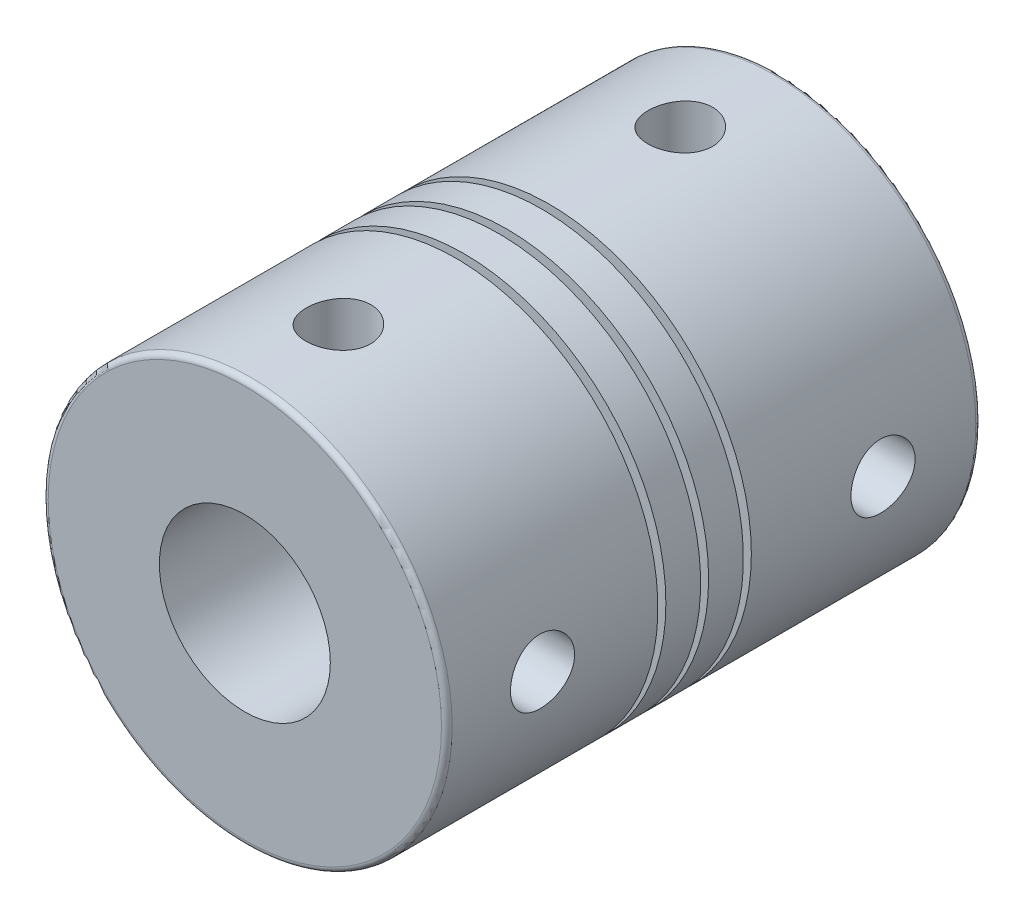
from build123d import *

# Parameters (mm, degrees)
ESQUISSE1_R             = 9.45
BOSS_EXTRU_1_DEPTH      = 25
CONG_1_R                = 0.25
ESQUISSE2_R             = 4
ENL_V_MAT_EXTRU_1_DEPTH = 17.5
ESQUISSE3_R             = 3
ENL_V_MAT_EXTRU_2_DEPTH = 17.5
ESQUISSE4_R             = 1.5
ENL_V_MAT_EXTRU_3_DEPTH = 10
ESQUISSE5_R             = 1.5
ENL_V_MAT_EXTRU_4_DEPTH = 10
ESQUISSE7_W             = 0.372914415
ESQUISSE7_H             = 1.339729566


with BuildPart() as part:
    # Esquisse1 → Boss.-Extru.1 (new body)
    with BuildSketch(Plane.XY):
        Circle(ESQUISSE1_R)
    extrude(amount=BOSS_EXTRU_1_DEPTH)

    # Congé1
    cong_1_edges = [part.edges().sort_by_distance(p)[0] for p in [
        (-9.45, 0, 0),
        (-9.45, 0, 25),
    ]]
    fillet(cong_1_edges, radius=CONG_1_R)

    # Esquisse2 → Enlèv. mat.-Extru.1 (cut)
    with BuildSketch(Plane.XY.offset(25)):
        Circle(ESQUISSE2_R)
    extrude(amount=-ENL_V_MAT_EXTRU_1_DEPTH, mode=Mode.SUBTRACT)

    # Esquisse3 → Enlèv. mat.-Extru.2 (cut)
    with BuildSketch(Plane(origin=(0, 0, 0), x_dir=(-1, 0, 0), z_dir=(0, 0, -1))):
        Circle(ESQUISSE3_R)
    extrude(amount=-ENL_V_MAT_EXTRU_2_DEPTH, mode=Mode.SUBTRACT)

    # Esquisse4 → Enlèv. mat.-Extru.3 (cut)
    with BuildSketch(Plane(origin=(9.45, 0, 0), x_dir=(0, 0, -1), z_dir=(1, 0, 0))):
        with Locations((-4.589130857, 0.014370537)):
            Circle(ESQUISSE4_R)
        with Locations((-20.520433185, 0.068499333)):
            Circle(ESQUISSE4_R)
    extrude(amount=-ENL_V_MAT_EXTRU_3_DEPTH, mode=Mode.SUBTRACT)

    # Esquisse5 → Enlèv. mat.-Extru.4 (cut)
    with BuildSketch(Plane(origin=(0, 9.45, 0), x_dir=(1, 0, 0), z_dir=(0, 1, 0))):
        with Locations((-0.124304805, -20.496942457)):
            Circle(ESQUISSE5_R)
        with Locations((-0.124304805, -4.503057543)):
            Circle(ESQUISSE5_R)
    extrude(amount=-ENL_V_MAT_EXTRU_4_DEPTH, mode=Mode.SUBTRACT)

    # Esquisse7 → Enlèvement de matière-Révolution1 (revolve, cut)
    with BuildSketch(Plane(origin=(0, 0, 0), x_dir=(0, 0, -1), z_dir=(1, 0, 0))):
        with Locations((-12.937755344, 9.16402646)):
            Rectangle(ESQUISSE7_W, ESQUISSE7_H)
        with Locations((-14.937755344, 9.16402646)):
            Rectangle(ESQUISSE7_W, ESQUISSE7_H)
        with Locations((-10.937755344, 9.16402646)):
            Rectangle(ESQUISSE7_W, ESQUISSE7_H)
    revolve(axis=Axis((0, 0, 25), (0, 0, -1)), mode=Mode.SUBTRACT)


solid = part.part
